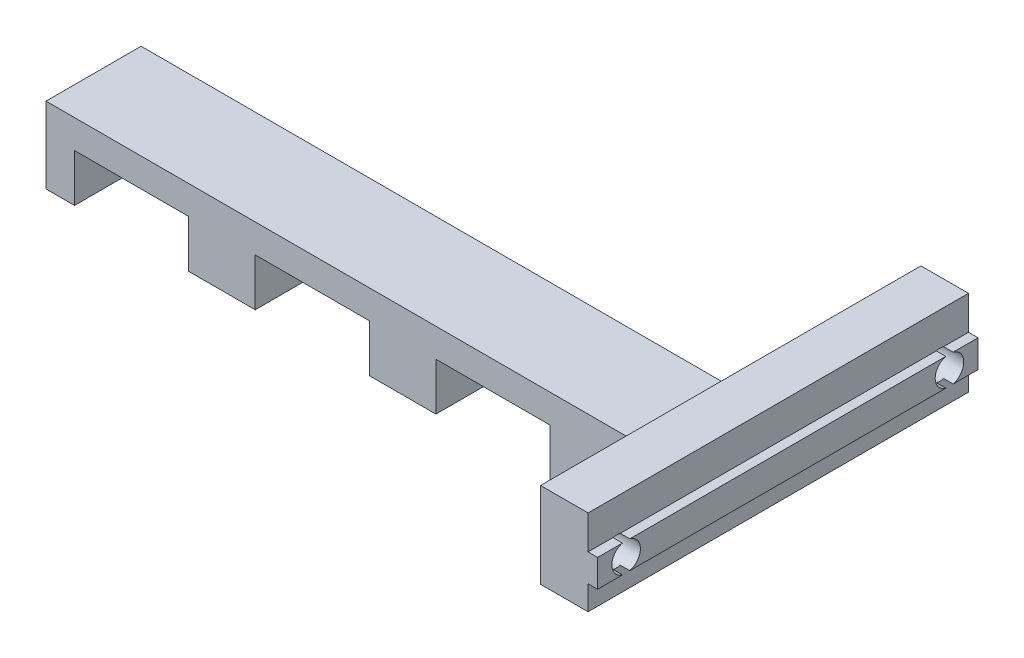
from build123d import *

# Parameters (mm, degrees)
MAIN_DEPTH             = 5
MAKERBEAMFIX_DEPTH     = 20
SKETCH2_R              = 1.5
MAKERBEAMFIXHOLE_DEPTH = 30
FILLET1_R              = 2


with BuildPart() as part:
    # Esquisse1 → Main (new body, symmetric)
    with BuildSketch(Plane.XY):
        Polygon((3, 0), (3, 5), (15, 5), (15, 0), (22, 0), (22, 5), (34, 5), (34, 0), (41, 0), (41, 5), (53, 5), (53, 0), (60, 0), (60, 5), (72, 5), (72, 8), (0, 8), (0, 0), align=None)
    extrude(amount=MAIN_DEPTH, both=True)

    # Sketch1 → MakerBeamFix (add, symmetric)
    with BuildSketch(Plane.XY):
        Polygon((67, 14), (72, 14), (72, 10.45), (73, 10.45), (73, 7.55), (72, 7.55), (72, 5), (67, 5), align=None)
    extrude(amount=MAKERBEAMFIX_DEPTH, both=True)

    # Sketch2 → MakerBeamFixHole (cut)
    with BuildSketch(Plane(origin=(73, 0, 0), x_dir=(0, 0, -1), z_dir=(1, 0, 0))):
        with Locations((-17, 9)):
            Circle(SKETCH2_R)
        with Locations((17, 9)):
            Circle(SKETCH2_R)
    extrude(amount=-MAKERBEAMFIXHOLE_DEPTH, mode=Mode.SUBTRACT)

    # Fillet1
    fillet1_edges = [part.edges().sort_by_distance(p)[0] for p in [
        (67, 6.5, -5),
        (67, 6.5, 5),
        (67, 8, 0),
    ]]
    fillet(fillet1_edges, radius=FILLET1_R)


solid = part.part
